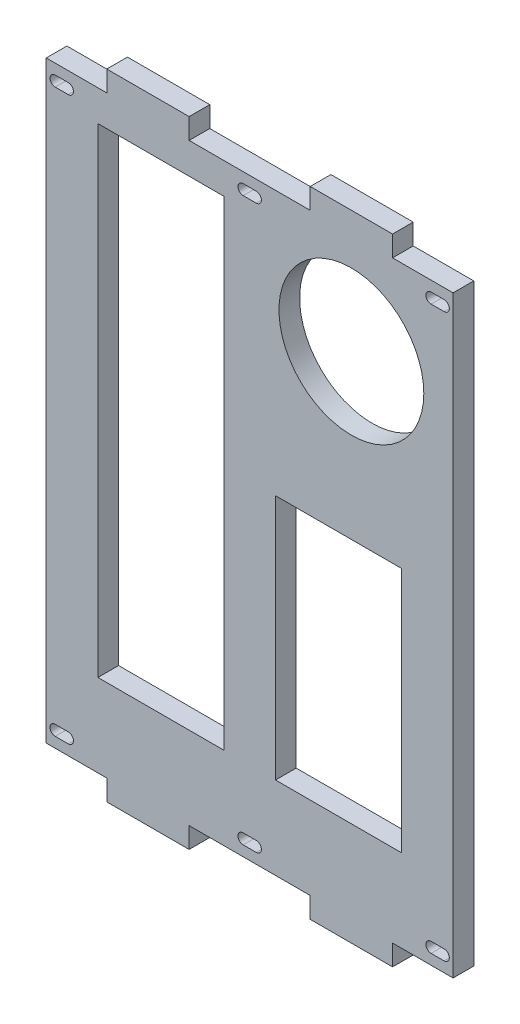
from build123d import *

# Parameters (mm, degrees)
CROQUIS1_W              = 250
CROQUIS1_H              = 390
CROQUIS1_R              = 44.5
CROQUIS1_W_2            = 77.375
CROQUIS1_H_2            = 294.75
CROQUIS1_H_3            = 151.3
SALIENTE_EXTRUIR1_DEPTH = 12.7
CROQUIS2_W              = 37.2
CROQUIS2_H              = 12.7
CROQUIS2_W_2            = 74.4
CORTAR_EXTRUIR1_DEPTH   = 13.7


with BuildPart() as part:
    # Croquis1 → Saliente-Extruir1 (new body)
    with BuildSketch(Plane.XY):
        Rectangle(CROQUIS1_W, CROQUIS1_H)
        with Locations((62.5, 119.8)):
            Circle(CROQUIS1_R, mode=Mode.SUBTRACT)
        with Locations((-54.5625, 15.875)):
            Rectangle(CROQUIS1_W_2, CROQUIS1_H_2, mode=Mode.SUBTRACT)
        with Locations((54.5625, -55.85)):
            Rectangle(CROQUIS1_W_2, CROQUIS1_H_3, mode=Mode.SUBTRACT)
    extrude(amount=SALIENTE_EXTRUIR1_DEPTH)

    # Croquis2 → Cortar-Extruir1 (cut, through all)
    with BuildSketch(Plane.XY.offset(12.7)):
        with Locations((-106.4, 188.65)):
            Rectangle(CROQUIS2_W, CROQUIS2_H)
        with Locations((0, 188.65)):
            Rectangle(CROQUIS2_W_2, CROQUIS2_H)
        with Locations((106.4, 188.65)):
            Rectangle(CROQUIS2_W, CROQUIS2_H)
        with BuildLine():
            Line((-119.475, 175.95), (-111.475, 175.95))
            ThreePointArc((-111.475, 175.95), (-108.275, 172.75), (-111.475, 169.55))
            Line((-111.475, 169.55), (-119.475, 169.55))
            ThreePointArc((-119.475, 169.55), (-122.675, 172.75), (-119.475, 175.95))
        make_face()
        with BuildLine():
            Line((-4, 175.95), (4, 175.95))
            ThreePointArc((4, 175.95), (7.2, 172.75), (4, 169.55))
            Line((4, 169.55), (-4, 169.55))
            ThreePointArc((-4, 169.55), (-7.2, 172.75), (-4, 175.95))
        make_face()
        with BuildLine():
            Line((111.475, 175.95), (119.475, 175.95))
            ThreePointArc((119.475, 175.95), (122.675, 172.75), (119.475, 169.55))
            Line((119.475, 169.55), (111.475, 169.55))
            ThreePointArc((111.475, 169.55), (108.275, 172.75), (111.475, 175.95))
        make_face()
    cortar_extruir1 = extrude(amount=-CORTAR_EXTRUIR1_DEPTH, mode=Mode.SUBTRACT)

    # Simetría1: Cortar-Extruir1 across plane
    add(cortar_extruir1.mirror(Plane.ZX), mode=Mode.SUBTRACT)


solid = part.part
